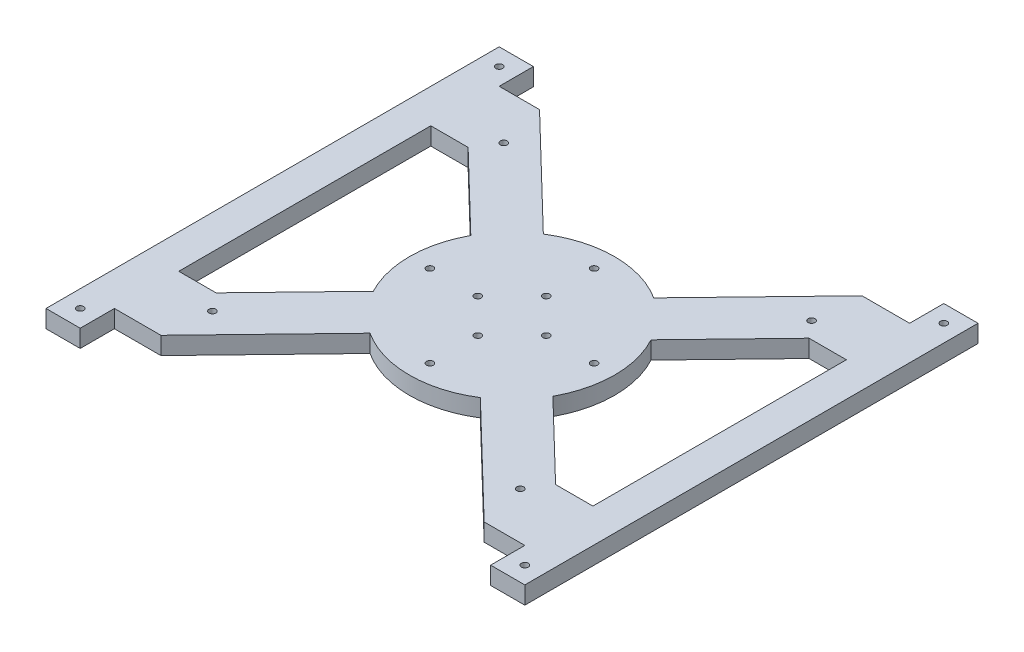
from build123d import *

# Parameters (mm, degrees)
SKETCH1_R           = 1.27
BOSS_EXTRUDE1_DEPTH = 6.5278


with BuildPart() as part:
    # Sketch1 → Boss-Extrude1 (new body)
    with BuildSketch(Plane(origin=(0, 0, 0), x_dir=(1, 0, 0), z_dir=(0, 1, 0))):
        with BuildLine():
            Line((177.8, 0), (165.1, 0))
            Line((165.1, 0), (165.1, 12.7))
            Line((165.1, 12.7), (149.996873526, 12.7))
            Line((149.996873526, 12.7), (109.316778017, 51.969733907))
            ThreePointArc((109.316778017, 51.969733907), (88.681426877, 46.038126963), (68.115490096, 52.206102473))
            Line((68.115490096, 52.206102473), (29.979047387, 12.7))
            Line((29.979047387, 12.7), (12.7, 12.7))
            Line((12.7, 12.7), (12.7, 0))
            Line((12.7, 0), (0, 0))
            Line((0, 0), (0, 12.7))
            Line((0, 12.7), (0, 155.575))
            Line((0, 155.575), (0, 168.275))
            Line((0, 168.275), (12.7, 168.275))
            Line((12.7, 168.275), (12.7, 155.575))
            Line((12.7, 155.575), (27.681767073, 155.575))
            Line((27.681767073, 155.575), (68.410076297, 116.258723928))
            ThreePointArc((68.410076297, 116.258723928), (88.928296157, 122.237489492), (109.437612749, 116.228253537))
            Line((109.437612749, 116.228253537), (147.420224254, 155.575))
            Line((147.420224254, 155.575), (165.1, 155.575))
            Line((165.1, 155.575), (165.1, 168.275))
            Line((165.1, 168.275), (177.8, 168.275))
            Line((177.8, 168.275), (177.8, 155.575))
            Line((177.8, 155.575), (177.8, 12.7))
            Line((177.8, 12.7), (177.8, 0))
        make_face()
        with Locations((101.6, 84.1375)):
            Circle(SKETCH1_R, mode=Mode.SUBTRACT)
        with Locations((88.9, 71.4375)):
            Circle(SKETCH1_R, mode=Mode.SUBTRACT)
        with Locations((76.2, 84.1375)):
            Circle(SKETCH1_R, mode=Mode.SUBTRACT)
        with Locations((88.9, 96.8375)):
            Circle(SKETCH1_R, mode=Mode.SUBTRACT)
        with Locations((119.38, 84.1375)):
            Circle(SKETCH1_R, mode=Mode.SUBTRACT)
        with Locations((88.9, 53.6575)):
            Circle(SKETCH1_R, mode=Mode.SUBTRACT)
        with Locations((58.42, 84.1375)):
            Circle(SKETCH1_R, mode=Mode.SUBTRACT)
        with Locations((88.9, 114.6175)):
            Circle(SKETCH1_R, mode=Mode.SUBTRACT)
        with Locations((171.45, 161.925)):
            Circle(SKETCH1_R, mode=Mode.SUBTRACT)
        with Locations((171.45, 6.35)):
            Circle(SKETCH1_R, mode=Mode.SUBTRACT)
        with Locations((6.35, 6.35)):
            Circle(SKETCH1_R, mode=Mode.SUBTRACT)
        with Locations((6.35, 161.925)):
            Circle(SKETCH1_R, mode=Mode.SUBTRACT)
        with Locations((146.05, 138.225892857)):
            Circle(SKETCH1_R, mode=Mode.SUBTRACT)
        with Locations((146.05, 30.049107143)):
            Circle(SKETCH1_R, mode=Mode.SUBTRACT)
        with Locations((31.75, 30.049107143)):
            Circle(SKETCH1_R, mode=Mode.SUBTRACT)
        with Locations((31.75, 138.225892857)):
            Circle(SKETCH1_R, mode=Mode.SUBTRACT)
        with BuildLine():
            Line((165.1, 132.097774838), (165.1, 37.982848079))
            Line((165.1, 37.982848079), (151.23481924, 37.982848079))
            Line((151.23481924, 37.982848079), (122.338925223, 65.876933745))
            ThreePointArc((122.338925223, 65.876933745), (126.999904752, 84.052306631), (122.420253584, 102.248342047))
            Line((122.420253584, 102.248342047), (151.23481924, 132.097774838))
            Line((151.23481924, 132.097774838), (165.1, 132.097774838))
        make_face(mode=Mode.SUBTRACT)
        with BuildLine():
            Line((12.7, 130.175), (12.7, 36.592345569))
            Line((12.7, 36.592345569), (26.56518076, 36.592345569))
            Line((26.56518076, 36.592345569), (55.23682207, 66.293720925))
            ThreePointArc((55.23682207, 66.293720925), (50.800488469, 84.330427734), (55.41925789, 102.321281448))
            Line((55.41925789, 102.321281448), (26.56518076, 130.175))
            Line((26.56518076, 130.175), (12.7, 130.175))
        make_face(mode=Mode.SUBTRACT)
    extrude(amount=BOSS_EXTRUDE1_DEPTH)


solid = part.part
